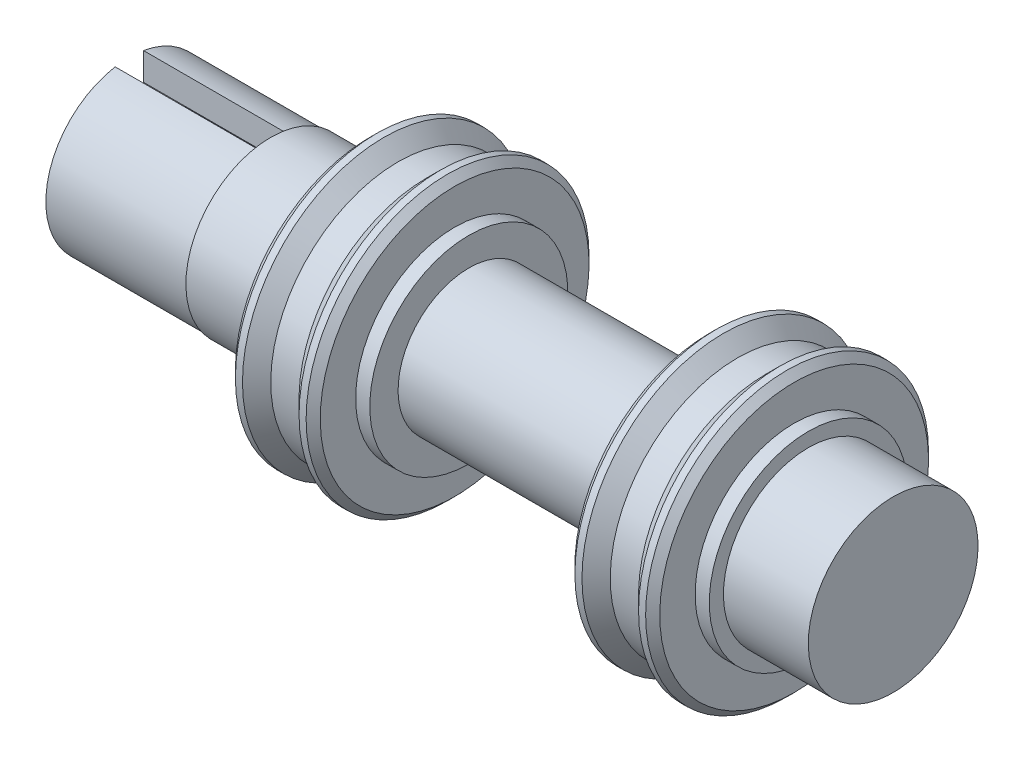
from build123d import *

# Parameters (mm, degrees)
FASE1_SIZE                      = 0.25
AUFSATZ_LINEAR_AUSTRAGEN1_DEPTH = 5


with BuildPart() as part:
    # Skizze1 → Rotation1 (revolve)
    with BuildSketch(Plane.XY):
        Polygon((-8, 3), (-11, 3), (-11, 0), (0, 0), (0, 2.5), (-4, 2.5), (-4, 3.5), (-4.5, 3.5), (-4.5, 5), (-5, 5), (-5.5, 4.5), (-6.5, 4.5), (-7, 5), (-7.5, 5), (-7.5, 3.5), (-8, 3.5), align=None)
    revolve(axis=Axis((-5.518776228, 0, 0), (-1, 0, 0)))

    # Fase1
    fase1_edges = [part.edges().sort_by_distance(p)[0] for p in [
        (-4.5, -5, 0),
        (-7.5, -5, 0),
    ]]
    chamfer(fase1_edges, length=FASE1_SIZE)

    # Spiegeln1: part across plane


with BuildPart() as part_1:
    add(part.part)
    add(part.part.mirror(Plane(origin=(0, 0, 0), x_dir=(0, 0, 1), z_dir=(1, 0, 0))))

    # Skizze2 → Aufsatz-Linear austragen1 (add)
    with BuildSketch(Plane.ZY.offset(11)):
        with BuildLine():
            Line((-0.5, -1.936491673), (-0.5, -2.907318352))
            ThreePointArc((-0.5, -2.907318352), (-2.95, 0), (-0.5, 2.907318352))
            Line((-0.5, 2.907318352), (-0.5, 1.936491673))
            ThreePointArc((-0.5, 1.936491673), (-2, 0), (-0.5, -1.936491673))
        make_face()
        with BuildLine():
            Line((0.5, -1.936491673), (0.5, -2.907318352))
            ThreePointArc((0.5, -2.907318352), (2.95, 0), (0.5, 2.907318352))
            Line((0.5, 2.907318352), (0.5, 1.936491673))
            ThreePointArc((0.5, 1.936491673), (2, 0), (0.5, -1.936491673))
        make_face()
    extrude(amount=AUFSATZ_LINEAR_AUSTRAGEN1_DEPTH)


solid = part_1.part
